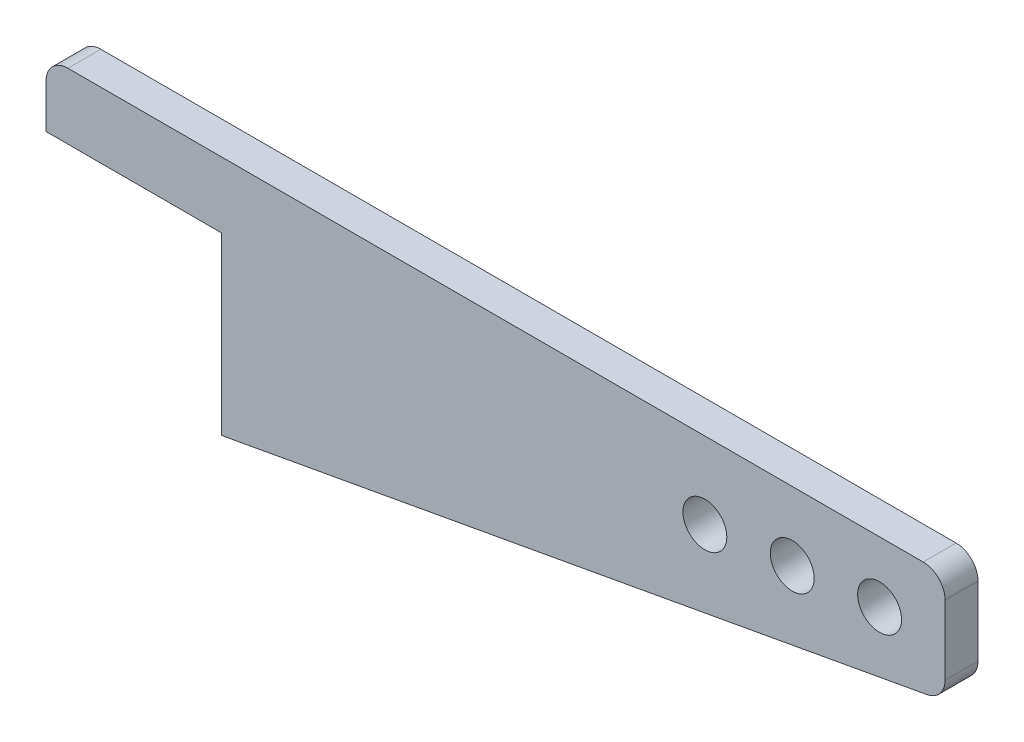
from build123d import *

# Parameters (mm, degrees)
ESQUISSE1_R        = 10
BOSS_EXTRU_1_DEPTH = 15
CONG_1_R           = 10


with BuildPart() as part:
    # Esquisse1 → Boss.-Extru.1 (new body)
    with BuildSketch(Plane.XY):
        Polygon((0, 0), (410, 0), (410, -50), (80, -110), (80, -30), (0, -30), align=None)
        with Locations((300.451747289, -34.958932065)):
            Circle(ESQUISSE1_R, mode=Mode.SUBTRACT)
        with Locations((340.287475547, -31.337502223)):
            Circle(ESQUISSE1_R, mode=Mode.SUBTRACT)
        with Locations((380.123203806, -27.716072381)):
            Circle(ESQUISSE1_R, mode=Mode.SUBTRACT)
    extrude(amount=BOSS_EXTRU_1_DEPTH)

    # Congé1
    cong_1_edges = [part.edges().sort_by_distance(p)[0] for p in [
        (0, 0, 7.5),
        (410, 0, 7.5),
        (410, -50, 7.5),
    ]]
    fillet(cong_1_edges, radius=CONG_1_R)


solid = part.part
